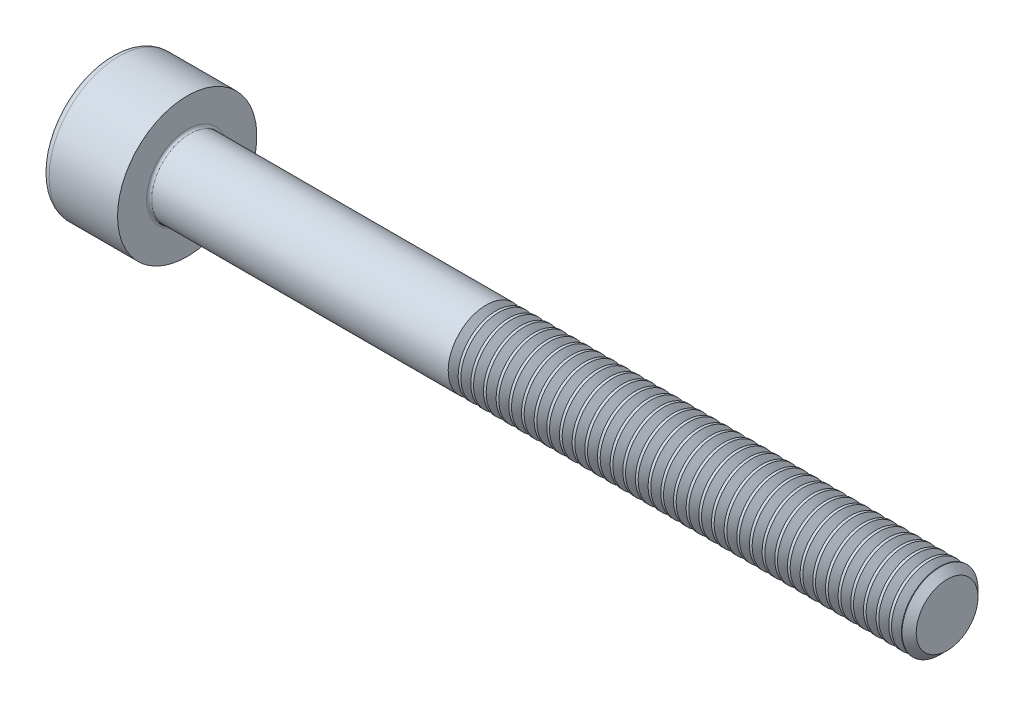
from build123d import *

# Parameters (mm, degrees)
FILLET1_R       = 0.1
FILLET2_R       = 0.3
HEX_2_DEPTH     = 1.3
THDSCHPAT_COUNT = 36
THDSCHPAT_PITCH = 0.5


with BuildPart() as part:
    # BodySke → Base-Revolve (revolve)
    with BuildSketch(Plane.XY):
        Polygon((0, 0), (0, 2.75), (3, 2.75), (3, 1.5), (32.7195, 1.5), (33, 1.2195), (33, 0), align=None)
    revolve(axis=Axis((-31.75, 0, 0), (1, 0, 0)))

    # Fillet1
    fillet1_edges = [part.edges().sort_by_distance(p)[0] for p in [
        (3, -1.5, 0),
    ]]
    fillet(fillet1_edges, radius=FILLET1_R)

    # Fillet2
    fillet2_edges = [part.edges().sort_by_distance(p)[0] for p in [
        (0, -2.75, 0),
    ]]
    fillet(fillet2_edges, radius=FILLET2_R)

    # Sketch2 → Hex-PreBroach (revolve, cut)
    with BuildSketch(Plane.XY):
        Polygon((0, 1.26), (1.3, 1.26), (2.027461339, 0), (0, 0), align=None)
    revolve(axis=Axis((0, 0, 0), (1, 0, 0)), mode=Mode.SUBTRACT)

    # Sketch3 → Hex 2 (cut)
    with BuildSketch(Plane(origin=(0, 0, 0), x_dir=(0, 0.5, 0.866025404), z_dir=(-1, 0, 0))):
        Polygon((0.727461339, 1.26), (-0.727461339, 1.26), (-1.454922678, 0), (-0.727461339, -1.26), (0.727461339, -1.26), (1.454922678, 0), align=None)
    extrude(amount=-HEX_2_DEPTH, mode=Mode.SUBTRACT)

    # ThdSchSke → ThreadSchematic (revolve, cut)
    with BuildSketch(Plane.XY):
        Polygon((15, -1.2195), (14.803591786, -1.5), (14.803591786, -1.875), (15.196408214, -1.875), (15.196408214, -1.5), align=None)
    threadschematic = revolve(axis=Axis((-3.175, 0, 0), (1, 0, 0)), mode=Mode.SUBTRACT)

    # ThdSchPat: ThreadSchematic ×36
    with Locations(*[(i * THDSCHPAT_PITCH, 0, 0) for i in range(1, THDSCHPAT_COUNT)]):
        add(threadschematic, mode=Mode.SUBTRACT)


solid = part.part
